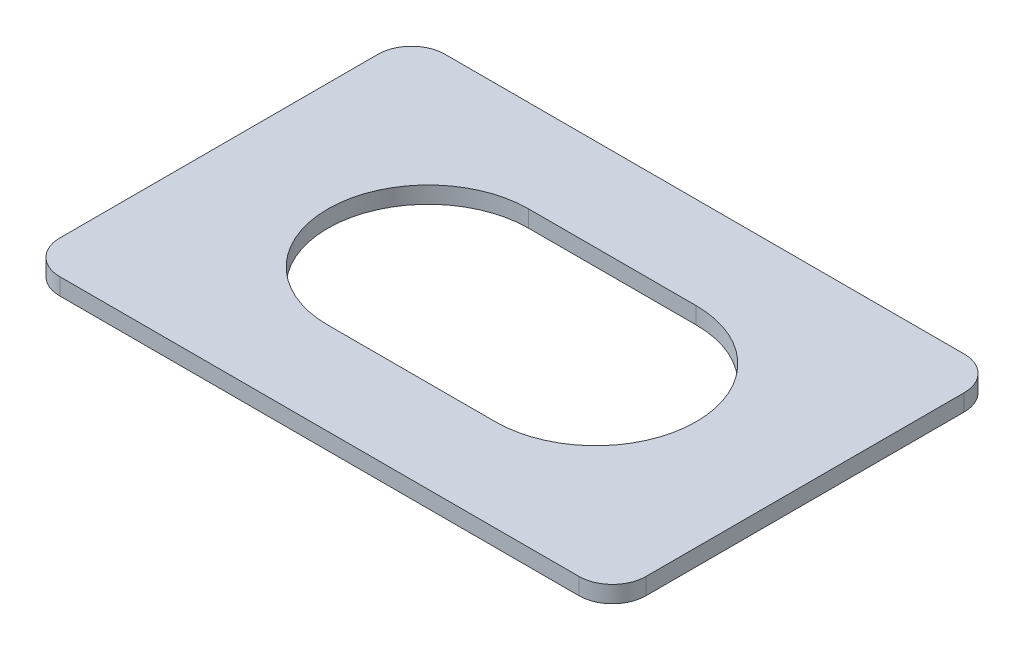
from build123d import *

# Parameters (mm, degrees)
EXTRUDE_1_DEPTH = 1


with BuildPart() as part:
    # Эскиз1 → Бобышка-Вытянуть1 (new body)
    with BuildSketch(Plane(origin=(0, 0, 0), x_dir=(1, 0, 0), z_dir=(0, 1, 0))):
        with BuildLine():
            Line((15.5, -11.5), (-15.5, -11.5))
            ThreePointArc((-15.5, -11.5), (-16.914213562, -10.914213562), (-17.5, -9.5))
            Line((-17.5, -9.5), (-17.5, 9.5))
            ThreePointArc((-17.5, 9.5), (-16.914213562, 10.914213562), (-15.5, 11.5))
            Line((-15.5, 11.5), (15.5, 11.5))
            ThreePointArc((15.5, 11.5), (16.914213562, 10.914213562), (17.5, 9.5))
            Line((17.5, 9.5), (17.5, -9.5))
            ThreePointArc((17.5, -9.5), (16.914213562, -10.914213562), (15.5, -11.5))
        make_face()
        with BuildLine():
            Line((-5, 6), (5, 6))
            ThreePointArc((5, 6), (11, 0), (5, -6))
            Line((5, -6), (-5, -6))
            ThreePointArc((-5, -6), (-11, 0), (-5, 6))
        make_face(mode=Mode.SUBTRACT)
    extrude(amount=EXTRUDE_1_DEPTH)


solid = part.part
